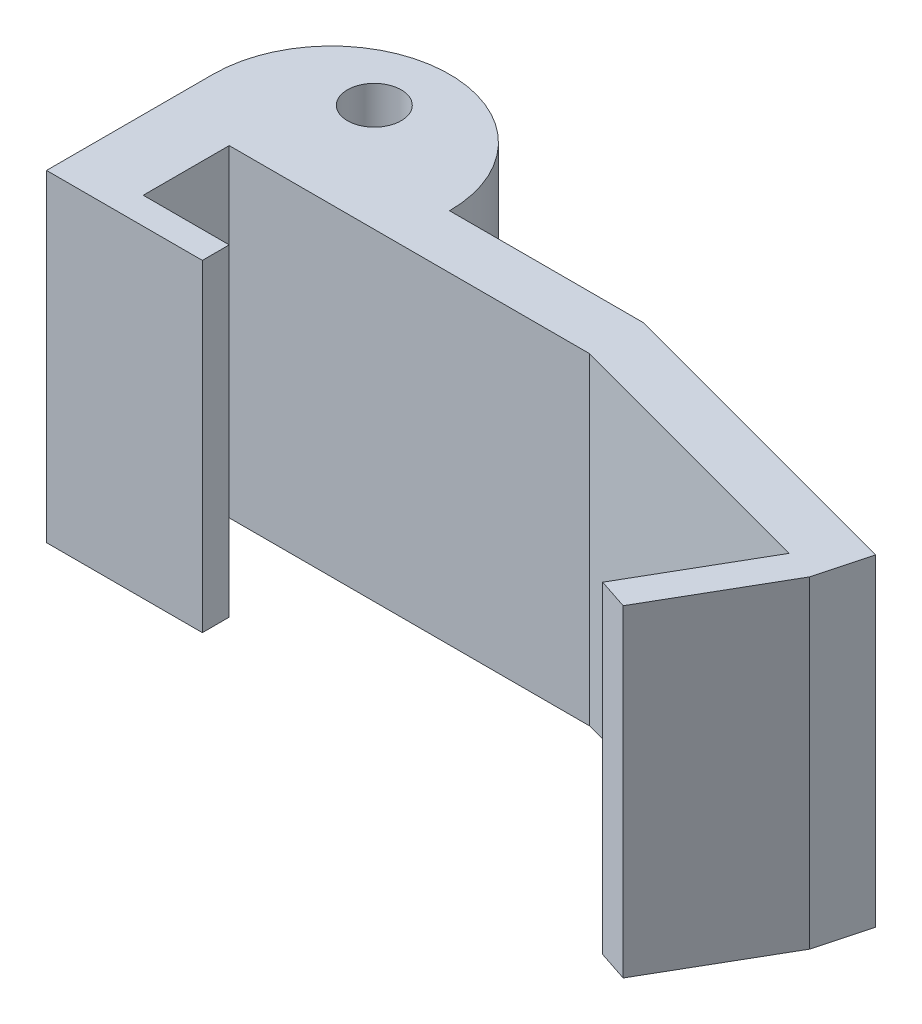
from build123d import *

# Parameters (mm, degrees)
SKETCH1_R           = 0.5
SKETCH1_W           = 1.6
SKETCH1_H           = 0.5
BOSS_EXTRUDE1_DEPTH = 6


with BuildPart() as part:
    # Sketch1 → Boss-Extrude1 (new body)
    with BuildSketch(Plane(origin=(0, 0, 0), x_dir=(1, 0, 0), z_dir=(0, 1, 0))):
        Polygon((4.4, 0), (0, 0), (0, -1), (1.3, -1), (8, -1), (13.081525469, -2.361590646), (13.651326592, -2.549544577), (13.910145637, -1.583618751), (8, 0), align=None)
        Polygon((1.3, -1), (0, -1), (0, -3.1), (1.3, -3.1), (1.3, -2.6), align=None)
        Polygon((12.381156, -4.749544577), (13.651326592, -2.549544577), (13.081525469, -2.361590646), (11.811354877, -4.561590646), align=None)
        with BuildLine():
            ThreePointArc((4.4, 0), (2.2, 2.2), (0, 0))
            Line((0, 0), (4.4, 0))
        make_face()
        with Locations((2, 1)):
            Circle(SKETCH1_R, mode=Mode.SUBTRACT)
        with Locations((2.1, -2.85)):
            Rectangle(SKETCH1_W, SKETCH1_H)
    extrude(amount=BOSS_EXTRUDE1_DEPTH)


solid = part.part
